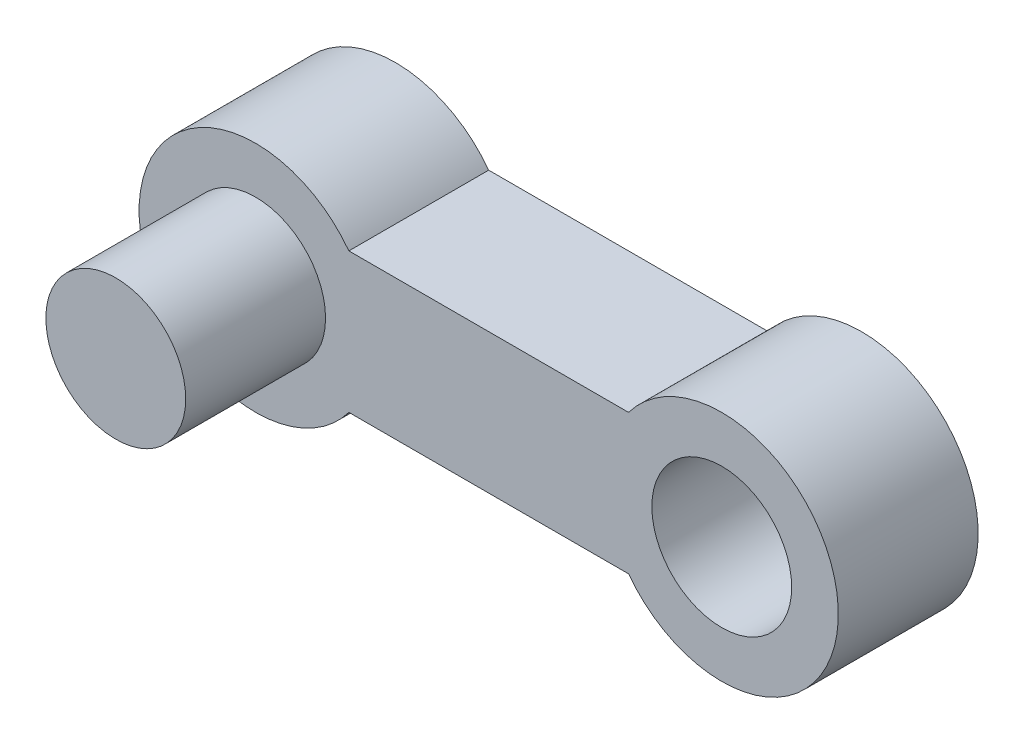
from build123d import *

# Parameters (mm, degrees)
BOSS_EXTRUDE1_DEPTH = 3
SKETCH3_R           = 1.5
BOSS_EXTRUDE2_DEPTH = 3
SKETCH4_R           = 1.5
CUT_EXTRUDE1_DEPTH  = 3


with BuildPart() as part:
    # Sketch2 → Boss-Extrude1 (new body)
    with BuildSketch(Plane.XY):
        with BuildLine():
            Line((-25.866686, 11.924208702), (-25.866686, 14.924208702))
            Line((-25.866686, 14.924208702), (-24.866686, 14.924208702))
            ThreePointArc((-24.866686, 14.924208702), (-29.366686, 13.424208702), (-24.866686, 11.924208702))
            Line((-24.866686, 11.924208702), (-25.866686, 11.924208702))
        make_face()
        with BuildLine():
            Line((-24.866686, 14.924208702), (-25.866686, 14.924208702))
            Line((-25.866686, 14.924208702), (-25.866686, 11.924208702))
            Line((-25.866686, 11.924208702), (-24.866686, 11.924208702))
            ThreePointArc((-24.866686, 11.924208702), (-24.494977755, 12.633639287), (-24.366686, 13.424208702))
            ThreePointArc((-24.366686, 13.424208702), (-24.494977755, 14.214778117), (-24.866686, 14.924208702))
        make_face()
        with BuildLine():
            Line((-18.866686, 14.924208702), (-24.866686, 14.924208702))
            ThreePointArc((-24.866686, 14.924208702), (-24.494977755, 14.214778117), (-24.366686, 13.424208702))
            ThreePointArc((-24.366686, 13.424208702), (-24.494977755, 12.633639287), (-24.866686, 11.924208702))
            Line((-24.866686, 11.924208702), (-18.866686, 11.924208702))
            ThreePointArc((-18.866686, 11.924208702), (-19.366686, 13.424208702), (-18.866686, 14.924208702))
        make_face()
        with BuildLine():
            ThreePointArc((-14.366686, 13.424208702), (-16.076116585, 15.795916947), (-18.866686, 14.924208702))
            Line((-18.866686, 14.924208702), (-17.866686, 14.924208702))
            Line((-17.866686, 14.924208702), (-17.866686, 11.924208702))
            Line((-17.866686, 11.924208702), (-18.866686, 11.924208702))
            ThreePointArc((-18.866686, 11.924208702), (-16.076116585, 11.052500457), (-14.366686, 13.424208702))
        make_face()
        with BuildLine():
            Line((-17.866686, 14.924208702), (-18.866686, 14.924208702))
            ThreePointArc((-18.866686, 14.924208702), (-19.366686, 13.424208702), (-18.866686, 11.924208702))
            Line((-18.866686, 11.924208702), (-17.866686, 11.924208702))
            Line((-17.866686, 11.924208702), (-17.866686, 14.924208702))
        make_face()
    extrude(amount=BOSS_EXTRUDE1_DEPTH)

    # Sketch3 → Boss-Extrude2 (add)
    with BuildSketch(Plane.XY.offset(3)):
        with Locations((-26.866686, 13.424208702)):
            Circle(SKETCH3_R)
    extrude(amount=BOSS_EXTRUDE2_DEPTH)

    # Sketch4 → Cut-Extrude1 (cut)
    with BuildSketch(Plane(origin=(0, 0, 0), x_dir=(-1, 0, 0), z_dir=(0, 0, -1))):
        with Locations((16.866686, 13.424208702)):
            Circle(SKETCH4_R)
    extrude(amount=-CUT_EXTRUDE1_DEPTH, mode=Mode.SUBTRACT)


solid = part.part
